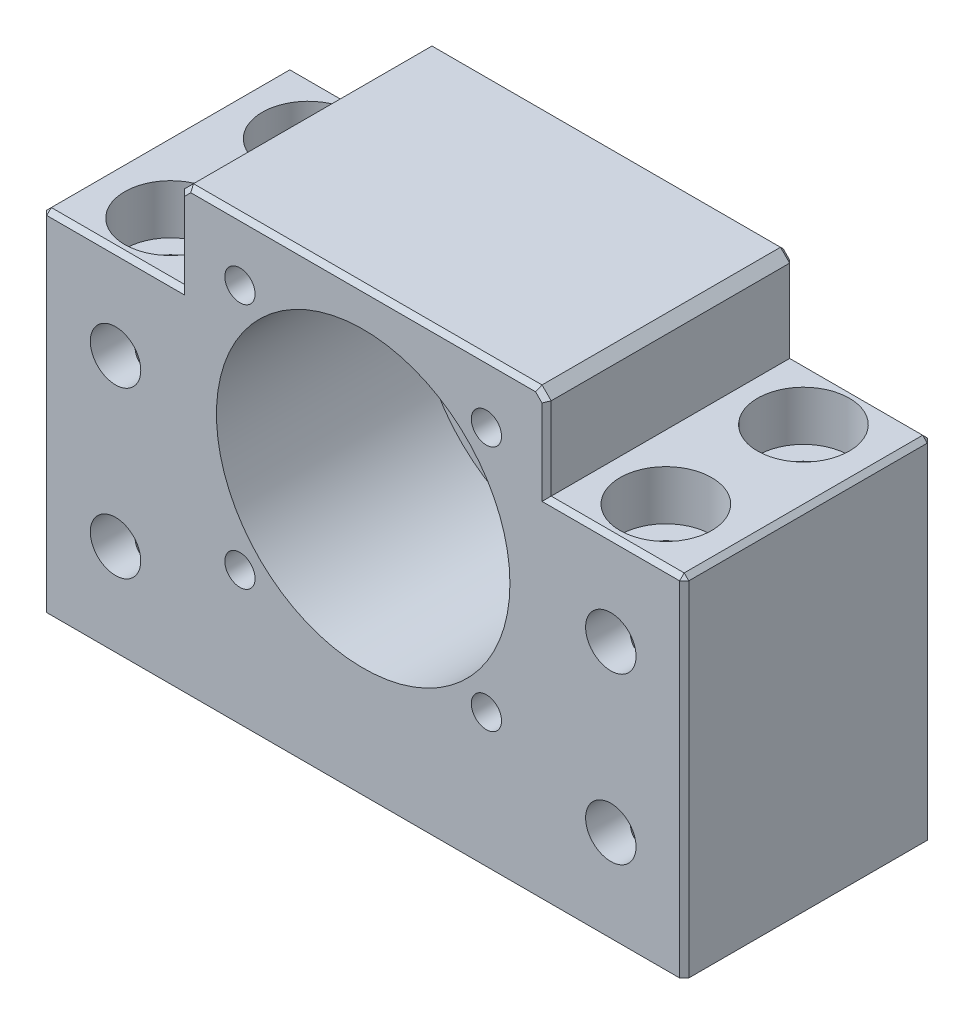
from build123d import *

# Parameters (mm, degrees)
SKETCH_1_R                   = 14
SKETCH_1_R_2                 = 2.75
EXTRUDE_1_DEPTH              = 27
CHAMFER_2_SIZE               = 1
HOLE_WIZARD_M5_4_D           = 5.5
HOLE_WIZARD_M5_4_CBORE_D     = 10
HOLE_WIZARD_M5_4_CBORE_DEPTH = 5.4
PATTERN_CIRCULAR_1_COUNT     = 4
SKETCH_15_R                  = 16
SKETCH_15_R_2                = 14
CUT_EXTRUDE_1_DEPTH          = 22
CHAMFER_3_SIZE               = 0.5


with BuildPart() as part:
    # 草圖1 → 填料-伸長1 (new body)
    with BuildSketch(Plane.XY):
        Polygon((55, 38), (70, 38), (70, 0), (0, 0), (0, 38), (15, 38), (15, 48), (55, 48), align=None)
        with Locations((35, 28)):
            Circle(SKETCH_1_R, mode=Mode.SUBTRACT)
        with Locations((8, 28)):
            Circle(SKETCH_1_R_2, mode=Mode.SUBTRACT)
        with Locations((62, 28)):
            Circle(SKETCH_1_R_2, mode=Mode.SUBTRACT)
        with Locations((8, 10)):
            Circle(SKETCH_1_R_2, mode=Mode.SUBTRACT)
        with Locations((62, 10)):
            Circle(SKETCH_1_R_2, mode=Mode.SUBTRACT)
    extrude(amount=-EXTRUDE_1_DEPTH)

    # 導角2
    chamfer_2_edges = [part.edges().sort_by_distance(p)[0] for p in [
        (15, 48, -13.5),
        (55, 48, -13.5),
    ]]
    chamfer(chamfer_2_edges, length=CHAMFER_2_SIZE)

    # M5 六角承窩頭蓋螺釘的柱孔4 (through all)
    with Locations(Plane(origin=(0, 38, 0), x_dir=(1, 0, 0), z_dir=(0, 1, 0))):
        with Locations((8, 21), (8, 6), (62, 21), (62, 6)):
            CounterBoreHole(HOLE_WIZARD_M5_4_D / 2, HOLE_WIZARD_M5_4_CBORE_D / 2, HOLE_WIZARD_M5_4_CBORE_DEPTH)

    # 草圖14 → M4 螺紋孔1 (revolve, cut)
    with BuildSketch(Plane(origin=(21.564971157, 41.435028843, 0), x_dir=(0, -1, 0), z_dir=(1, 0, 0))):
        Polygon((0, 0), (0, 12.991420021), (1.65, 12), (1.65, 0), align=None)
    hole_wizard_m4_1 = revolve(axis=Axis((21.564971157, 41.435028843, 6.35), (0, 0, -1)), mode=Mode.SUBTRACT)

    # 環狀複製排列1: M4 螺紋孔1 ×4 about axis
    pattern_circular_1_axis = Axis((35, 28, 0), (0, 0, 1))
    for i in range(1, PATTERN_CIRCULAR_1_COUNT):
        add(hole_wizard_m4_1.rotate(pattern_circular_1_axis, i * 360 / PATTERN_CIRCULAR_1_COUNT), mode=Mode.SUBTRACT)

    # 草圖15 → 除料-伸長1 (cut)
    with BuildSketch(Plane.XY):
        with Locations((35, 28)):
            Circle(SKETCH_15_R)
        with Locations((35, 28)):
            Circle(SKETCH_15_R_2, mode=Mode.SUBTRACT)
    extrude(amount=-CUT_EXTRUDE_1_DEPTH, mode=Mode.SUBTRACT)

    # 導角3
    chamfer_3_edges = [part.edges().sort_by_distance(p)[0] for p in [
        (70, 19, -27),
        (0, 19, 0),
        (62.5, 38, -27),
        (0, 38, -13.5),
        (70, 38, -13.5),
        (55, 42.5, -27),
        (7.5, 38, -27),
        (0, 19, -27),
        (35, 48, 0),
        (35, 48, -27),
        (15, 42.5, 0),
        (54.5, 47.5, 0),
        (15.5, 47.5, 0),
        (15, 42.5, -27),
        (54.5, 47.5, -27),
        (15.5, 47.5, -27),
        (7.5, 38, 0),
        (55, 42.5, 0),
        (62.5, 38, 0),
        (70, 19, 0),
    ]]
    chamfer(chamfer_3_edges, length=CHAMFER_3_SIZE)


solid = part.part
